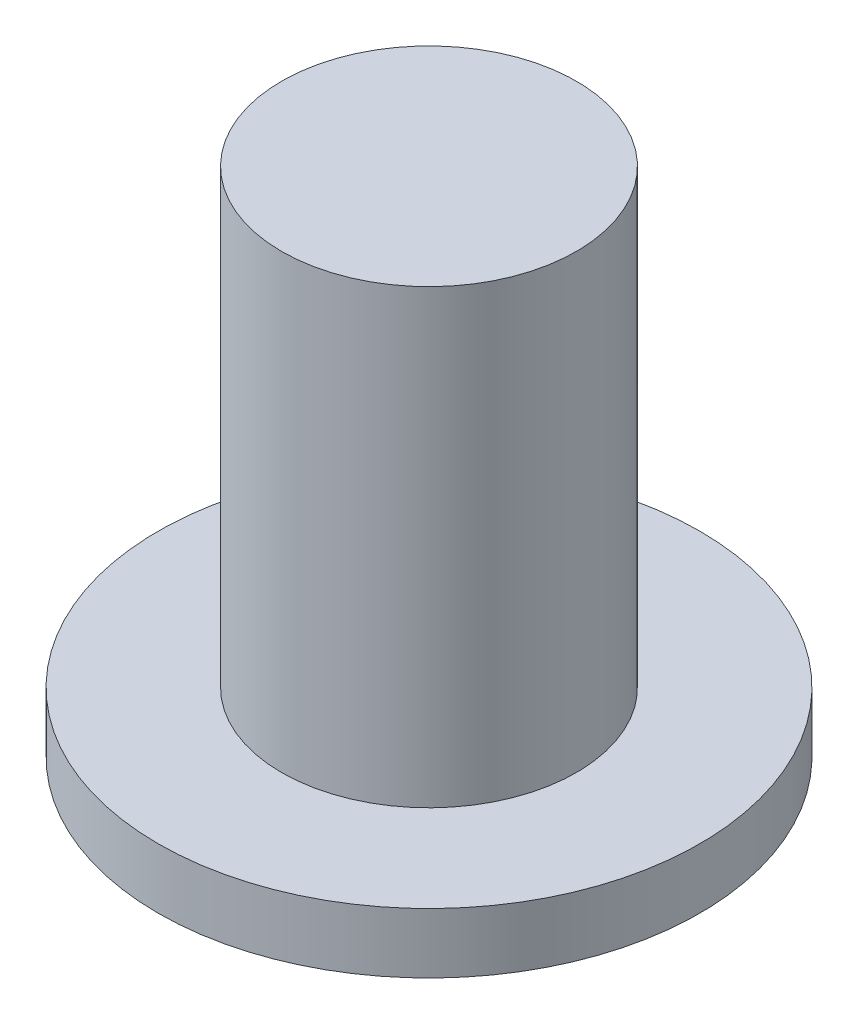
from build123d import *

# Parameters (mm, degrees)
SKICA1_R                = 9
P_IDAT_VYSUNUT_M1_DEPTH = 2
SKICA2_R                = 4.9
P_IDAT_VYSUNUT_M2_DEPTH = 15


with BuildPart() as part:
    # Skica1 → Přidat vysunutím1 (new body)
    with BuildSketch(Plane(origin=(0, 0, 0), x_dir=(1, 0, 0), z_dir=(0, 1, 0))):
        Circle(SKICA1_R)
    extrude(amount=P_IDAT_VYSUNUT_M1_DEPTH)

    # Skica2 → Přidat vysunutím2 (add)
    with BuildSketch(Plane(origin=(0, 2, 0), x_dir=(1, 0, 0), z_dir=(0, 1, 0))):
        Circle(SKICA2_R)
    extrude(amount=P_IDAT_VYSUNUT_M2_DEPTH)


solid = part.part
